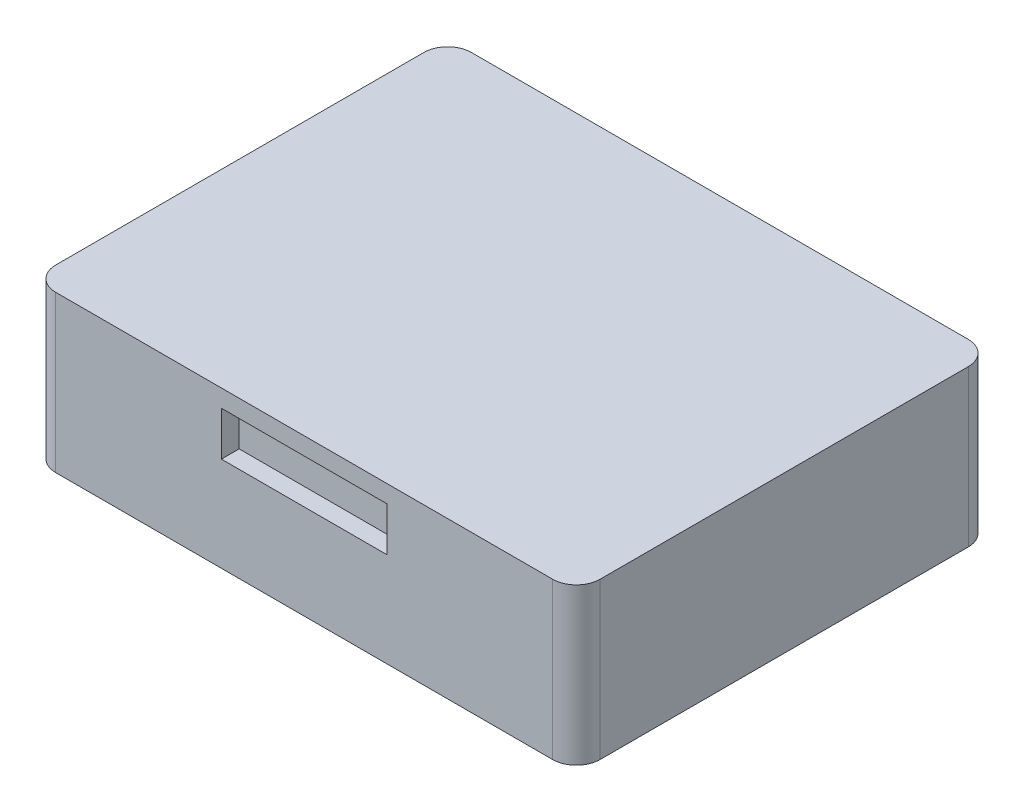
from build123d import *

# Parameters (mm, degrees)
SKETCH1_W           = 46
SKETCH1_H           = 35.12
BOSS_EXTRUDE1_DEPTH = 13.2
SKETCH2_W           = 13.25
SKETCH2_H           = 5.33
CUT_EXTRUDE1_DEPTH  = 1.5
SKETCH5_W           = 13.25
SKETCH5_H           = 5.33
CUT_EXTRUDE2_DEPTH  = 1.5
SKETCH6_W           = 14
SKETCH6_H           = 3.726009738
CUT_EXTRUDE3_DEPTH  = 1.5
FILLET1_R           = 2


with BuildPart() as part:
    # Sketch1 → Boss-Extrude1 (new body)
    with BuildSketch(Plane(origin=(0, 0, 0), x_dir=(1, 0, 0), z_dir=(0, 1, 0))):
        Rectangle(SKETCH1_W, SKETCH1_H)
    extrude(amount=BOSS_EXTRUDE1_DEPTH)

    # Sketch2 → Cut-Extrude1 (cut)
    with BuildSketch(Plane(origin=(0, 0, -17.56), x_dir=(-1, 0, 0), z_dir=(0, 0, -1))):
        with Locations((-10.945153605, 8.923987955)):
            Rectangle(SKETCH2_W, SKETCH2_H)
    extrude(amount=-CUT_EXTRUDE1_DEPTH, mode=Mode.SUBTRACT)

    # Sketch5 → Cut-Extrude2 (cut)
    with BuildSketch(Plane(origin=(0, 0, -17.56), x_dir=(-1, 0, 0), z_dir=(0, 0, -1))):
        with Locations((10.446134444, 8.878725803)):
            Rectangle(SKETCH5_W, SKETCH5_H)
    extrude(amount=-CUT_EXTRUDE2_DEPTH, mode=Mode.SUBTRACT)

    # Sketch6 → Cut-Extrude3 (cut)
    with BuildSketch(Plane.XY.offset(17.56)):
        with Locations((0, 9.85493568)):
            Rectangle(SKETCH6_W, SKETCH6_H)
    extrude(amount=-CUT_EXTRUDE3_DEPTH, mode=Mode.SUBTRACT)

    # Fillet1
    fillet1_edges = [part.edges().sort_by_distance(p)[0] for p in [
        (-23, 6.6, -17.56),
        (23, 6.6, -17.56),
        (23, 6.6, 17.56),
        (-23, 6.6, 17.56),
    ]]
    fillet(fillet1_edges, radius=FILLET1_R)


solid = part.part
